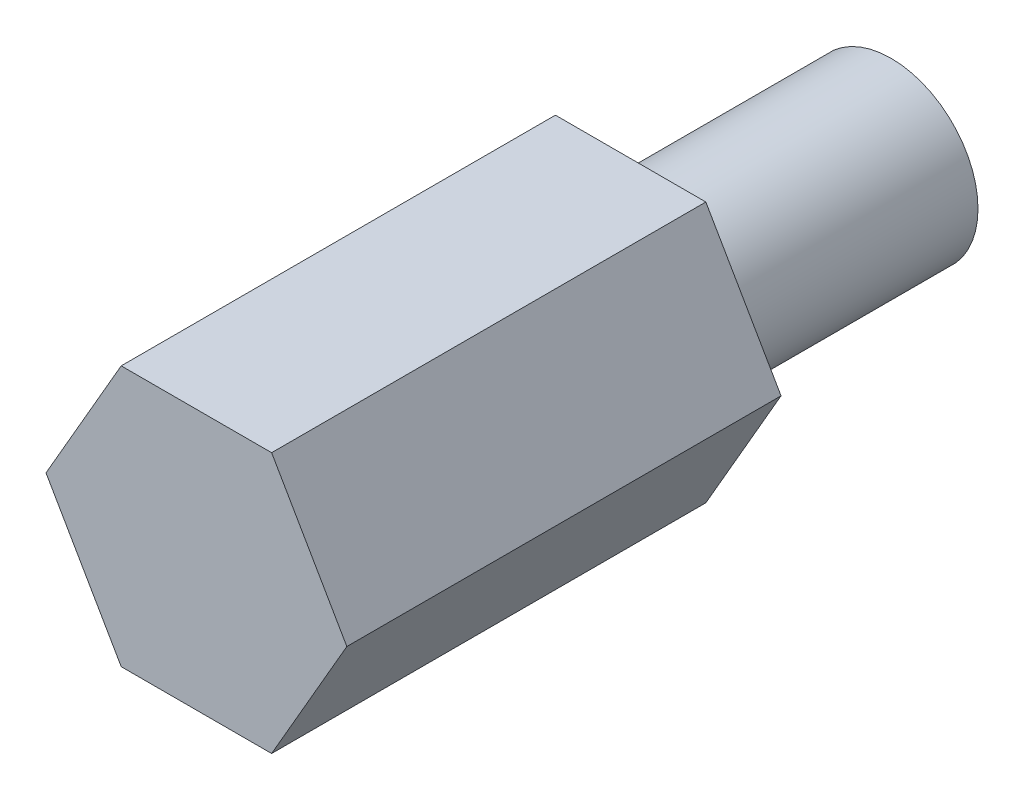
from build123d import *

# Parameters (mm, degrees)
EXTRUDE_1_DEPTH = 5
SKETCH_3_R      = 1
EXTRUDE_2_DEPTH = 3


with BuildPart() as part:
    # 草图2 → 凸台-拉伸1 (new body)
    with BuildSketch(Plane.XY):
        Polygon((1.732050808, 0), (0.866025404, 1.5), (-0.866025404, 1.5), (-1.732050808, 0), (-0.866025404, -1.5), (0.866025404, -1.5), align=None)
    extrude(amount=EXTRUDE_1_DEPTH)

    # 草图3 → 凸台-拉伸2 (add)
    with BuildSketch(Plane(origin=(0, 0, 0), x_dir=(-1, 0, 0), z_dir=(0, 0, -1))):
        Circle(SKETCH_3_R)
    extrude(amount=EXTRUDE_2_DEPTH)


solid = part.part
